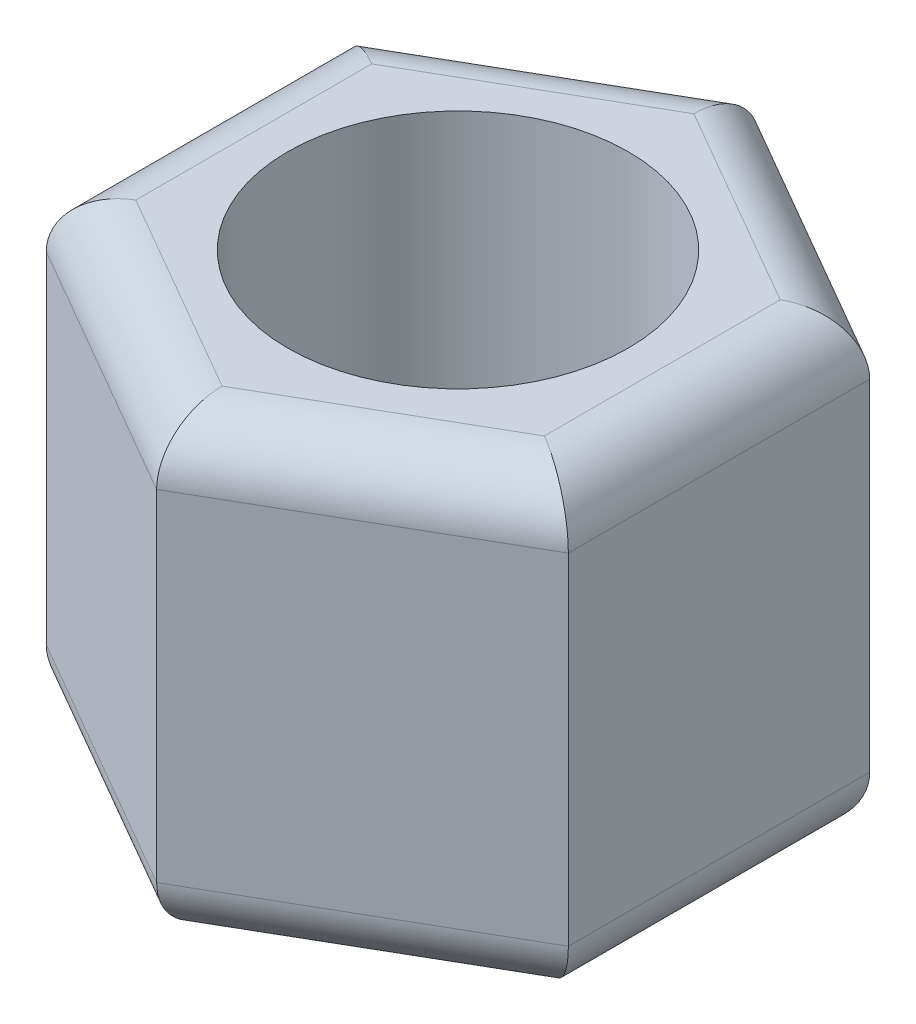
from build123d import *

# Parameters (mm, degrees)
SKETCH_1_R      = 1.5
EXTRUDE_1_DEPTH = 4
FILLET_1_R      = 0.5


with BuildPart() as part:
    # 草图1 → 凸台-拉伸1 (new body)
    with BuildSketch(Plane(origin=(0, 0, 0), x_dir=(1, 0, 0), z_dir=(0, 1, 0))):
        Polygon((2.3, -1.327905619), (2.3, 1.327905619), (0, 2.655811238), (-2.3, 1.327905619), (-2.3, -1.327905619), (0, -2.655811238), align=None)
        Circle(SKETCH_1_R, mode=Mode.SUBTRACT)
    extrude(amount=EXTRUDE_1_DEPTH)

    # 圆角1
    fillet_1_edges = [part.edges().sort_by_distance(p)[0] for p in [
        (1.15, 4, -1.991858429),
        (-1.15, 4, -1.991858429),
        (-2.3, 4, 0),
        (-1.15, 4, 1.991858429),
        (1.15, 4, 1.991858429),
        (-1.15, 0, 1.991858429),
        (-2.3, 0, 0),
        (-1.15, 0, -1.991858429),
        (1.15, 0, -1.991858429),
        (2.3, 0, 0),
        (1.15, 0, 1.991858429),
        (2.3, 4, 0),
    ]]
    fillet(fillet_1_edges, radius=FILLET_1_R)


solid = part.part
